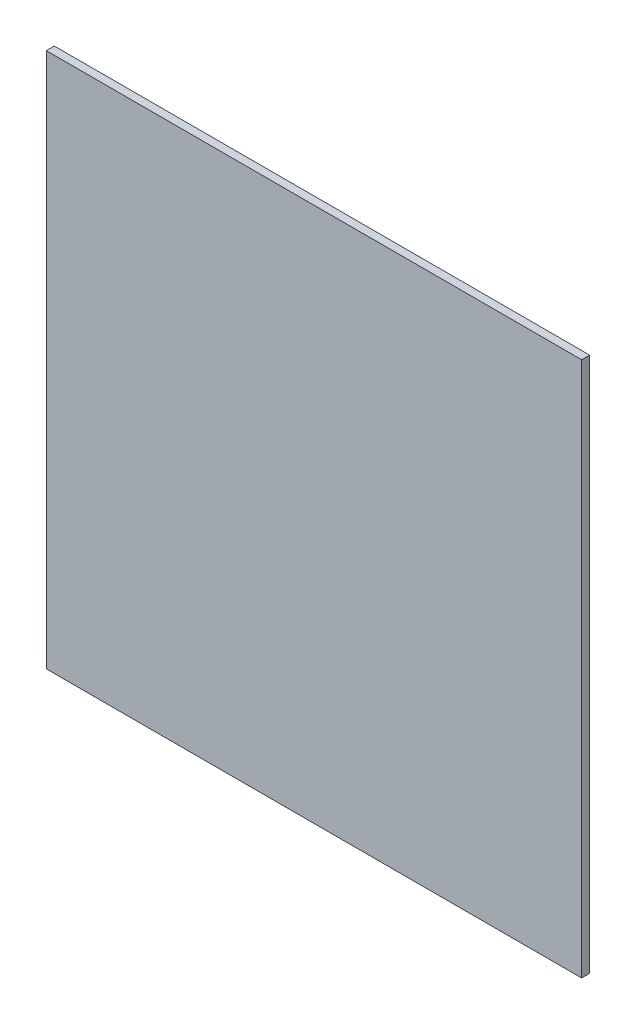
from build123d import *

# Parameters (mm, degrees)
ESQUISSE1_W        = 200
ESQUISSE1_H        = 200
BOSS_EXTRU_1_DEPTH = 3


with BuildPart() as part:
    # Esquisse1 → Boss.-Extru.1 (new body)
    with BuildSketch(Plane.XY):
        with Locations((-6.986846764, -395.605276029)):
            Rectangle(ESQUISSE1_W, ESQUISSE1_H)
    extrude(amount=BOSS_EXTRU_1_DEPTH)


solid = part.part
